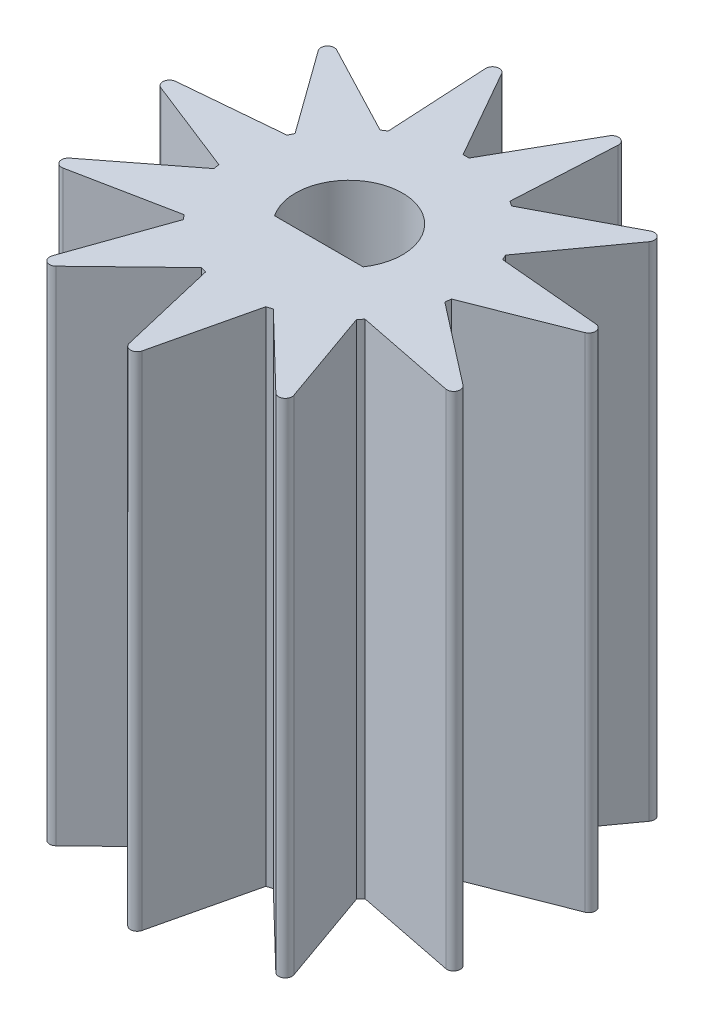
from build123d import *

# Parameters (mm, degrees)
ESBO_O1_W                = 1.9
ESBO_O1_H                = 15
RESSALTO_EXTRUS_O1_DEPTH = 15
PADR_OCIRCULAR1_COUNT    = 11
RESSALTO_EXTRUS_O2_DEPTH = 15


with BuildPart() as part:
    # Esboço1 → Revolução1 (revolve)
    with BuildSketch(Plane.XY):
        with Locations((2.55, 7.5)):
            Rectangle(ESBO_O1_W, ESBO_O1_H)
    revolve(axis=Axis((0, 0, 0), (0, 1, 0)))

    # Esboço3 → Ressalto-extrusão1 (add)
    with BuildSketch(Plane(origin=(0, 0, 0), x_dir=(-1, 0, 0), z_dir=(0, -1, 0))):
        with BuildLine():
            Line((-0.194663871, -6.374258983), (-0.9, -3.382306905))
            ThreePointArc((-0.9, -3.382306905), (0, -3.5), (0.9, -3.382306905))
            Line((0.9, -3.382306905), (0.194663871, -6.374258983))
            ThreePointArc((0.194663871, -6.374258983), (0, -6.528368053), (-0.194663871, -6.374258983))
        make_face()
    extrude(amount=-RESSALTO_EXTRUS_O1_DEPTH)

    # PadrãoCircular1: part ×11 about axis
    padr_ocircular1_axis = Axis((0, 0, 0), (0, 1, 0))


with BuildPart() as part_1:
    add(part.part)
    for i in range(1, PADR_OCIRCULAR1_COUNT):
        add(part.part.rotate(padr_ocircular1_axis, i * 360 / PADR_OCIRCULAR1_COUNT))

    # Esboço4 → Ressalto-extrusão2 (add)
    with BuildSketch(Plane.XZ):
        with BuildLine():
            Line((1.322875656, 0.9), (-1.322875656, 0.9))
            ThreePointArc((-1.322875656, 0.9), (0, 1.6), (1.322875656, 0.9))
        make_face()
    extrude(amount=-RESSALTO_EXTRUS_O2_DEPTH)


solid = part_1.part
